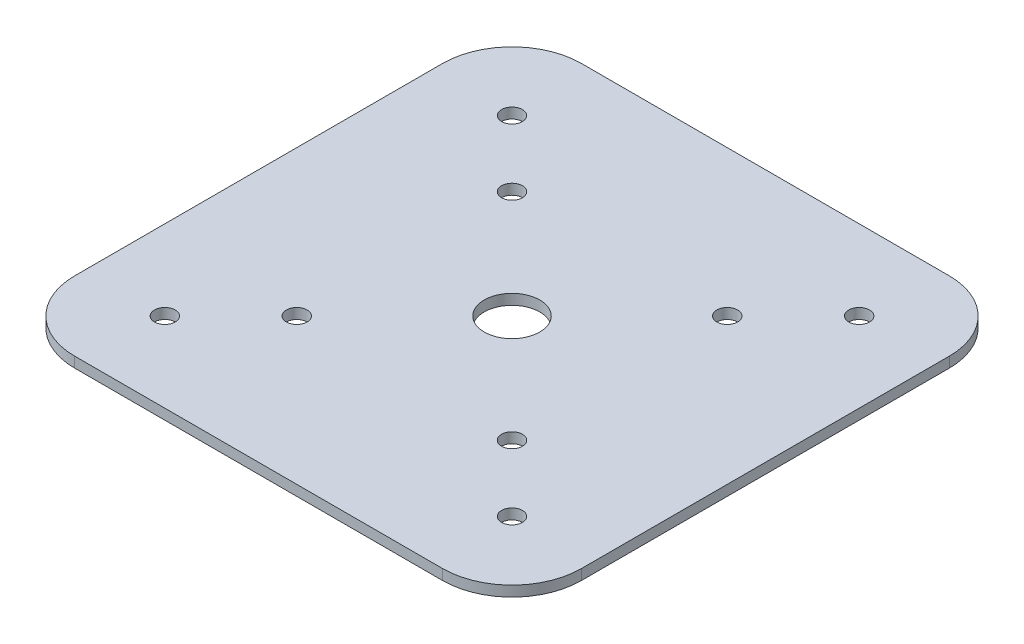
from build123d import *

# Parameters (mm, degrees)
SKETCH2_W           = 73
SKETCH2_H           = 73
SKETCH2_R           = 4
BOSS_EXTRUDE1_DEPTH = 1.5
SKETCH3_R           = 1.5
CUT_EXTRUDE1_DEPTH  = 2.5
SKETCH4_R           = 1.5
CUT_EXTRUDE2_DEPTH  = 2.5
FILLET1_R           = 10


with BuildPart() as part:
    # Sketch2 → Boss-Extrude1 (new body)
    with BuildSketch(Plane(origin=(0, 0, 0), x_dir=(1, 0, 0), z_dir=(0, 1, 0))):
        Rectangle(SKETCH2_W, SKETCH2_H)
        Circle(SKETCH2_R, mode=Mode.SUBTRACT)
    extrude(amount=BOSS_EXTRUDE1_DEPTH)

    # Sketch3 → Cut-Extrude1 (cut, through all)
    with BuildSketch(Plane(origin=(0, 1.5, 0), x_dir=(1, 0, 0), z_dir=(0, 1, 0))):
        with Locations((-15.5, 15.5)):
            Circle(SKETCH3_R)
        with Locations((15.5, 15.5)):
            Circle(SKETCH3_R)
        with Locations((15.5, -15.5)):
            Circle(SKETCH3_R)
        with Locations((-15.5, -15.5)):
            Circle(SKETCH3_R)
    extrude(amount=-CUT_EXTRUDE1_DEPTH, mode=Mode.SUBTRACT)

    # Sketch4 → Cut-Extrude2 (cut, through all)
    with BuildSketch(Plane(origin=(0, 1.5, 0), x_dir=(1, 0, 0), z_dir=(0, 1, 0))):
        with Locations((-25, 25)):
            Circle(SKETCH4_R)
        with Locations((25, 25)):
            Circle(SKETCH4_R)
        with Locations((25, -25)):
            Circle(SKETCH4_R)
        with Locations((-25, -25)):
            Circle(SKETCH4_R)
    extrude(amount=-CUT_EXTRUDE2_DEPTH, mode=Mode.SUBTRACT)

    # Fillet1
    fillet1_edges = [part.edges().sort_by_distance(p)[0] for p in [
        (36.5, 0.75, 36.5),
        (-36.5, 0.75, 36.5),
        (-36.5, 0.75, -36.5),
        (36.5, 0.75, -36.5),
    ]]
    fillet(fillet1_edges, radius=FILLET1_R)


solid = part.part
